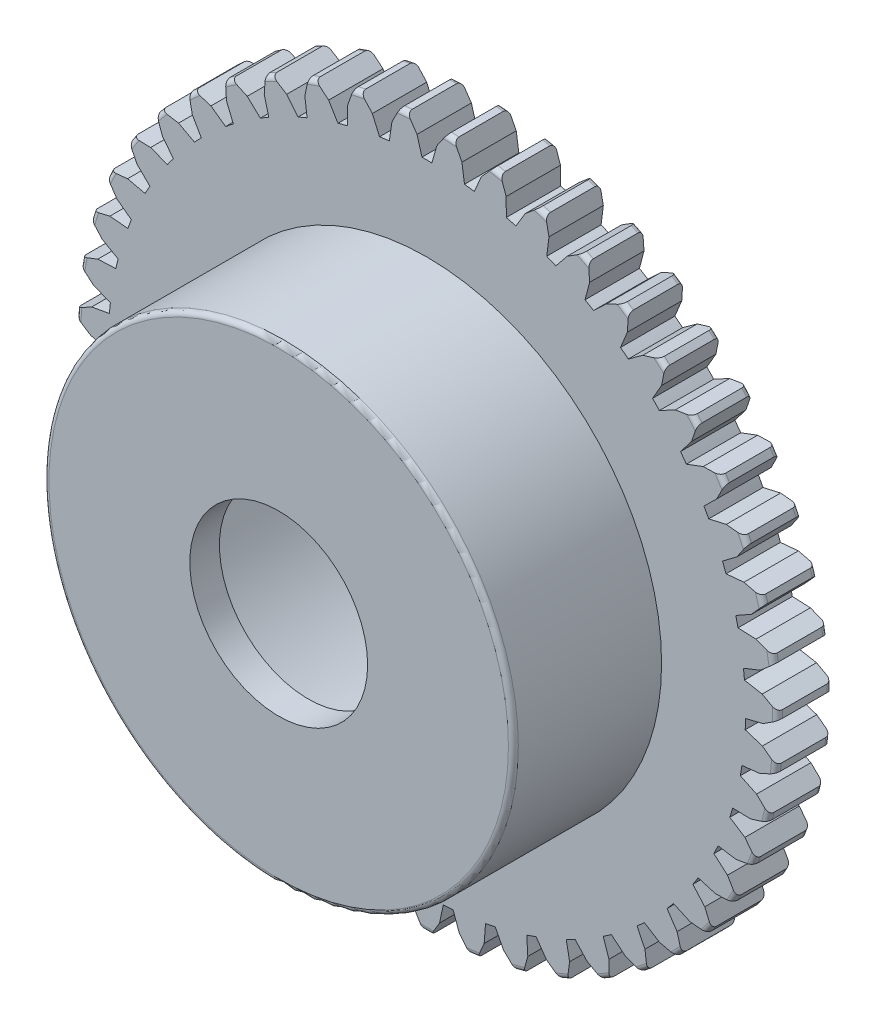
from build123d import *

# Parameters (mm, degrees)
CROQUIS1_R              = 7.1
CROQUIS1_R_2            = 4
SALIENTE_EXTRUIR1_DEPTH = 1.1
CORTAR_EXTRUIR1_DEPTH   = 1.1
REDONDEO2_R             = 0.1
MATRIZC1_COUNT          = 47
CROQUIS4_R              = 4.75
SALIENTE_EXTRUIR2_DEPTH = 3
REDONDEO3_R             = 0.1
CROQUIS2_6_R            = 1.8
CORTAR_EXTRUIR3_DEPTH   = 4.5
CROQUIS1_4_R            = 4
CORTAR_EXTRUIR4_DEPTH   = 3.5


with BuildPart() as part:
    # Croquis1 → Saliente-Extruir1 (new body)
    with BuildSketch(Plane.XY):
        Circle(CROQUIS1_R)
        Circle(CROQUIS1_R_2, mode=Mode.SUBTRACT)
    extrude(amount=SALIENTE_EXTRUIR1_DEPTH)

    # Croquis2 → Cortar-Extruir1 (cut)
    with BuildSketch(Plane.XY.offset(1.1)):
        with BuildLine():
            Line((0.4, 7.088723439), (0.4, 7.202922643))
            Line((0.4, 7.202922643), (-0.4, 7.202922643))
            Line((-0.4, 7.202922643), (-0.4, 7.088723439))
            Line((-0.4, 7.088723439), (-0.2, 6.8))
            Line((-0.2, 6.8), (-0.1, 6.44922476))
            ThreePointArc((-0.1, 6.44922476), (0, 6.45), (0.1, 6.44922476))
            Line((0.1, 6.44922476), (0.2, 6.8))
            Line((0.2, 6.8), (0.4, 7.088723439))
        make_face()
    cortar_extruir1 = extrude(amount=-CORTAR_EXTRUIR1_DEPTH, mode=Mode.SUBTRACT)

    # Redondeo2
    redondeo2_edges = [part.edges().sort_by_distance(p)[0] for p in [
        (0, -7.1, 0),
        (0, -7.1, 1.1),
    ]]
    fillet(redondeo2_edges, radius=REDONDEO2_R)

    # MatrizC1: Cortar-Extruir1 ×47 about axis
    matrizc1_axis = Axis((0, 0, 0), (0, 0, 1))
    for i in range(1, MATRIZC1_COUNT):
        add(cortar_extruir1.rotate(matrizc1_axis, i * 360 / MATRIZC1_COUNT), mode=Mode.SUBTRACT)

    # Croquis4 → Saliente-Extruir2 (add)
    with BuildSketch(Plane.XY.offset(1.1)):
        Circle(CROQUIS4_R)
    extrude(amount=SALIENTE_EXTRUIR2_DEPTH)

    # Redondeo3
    redondeo3_edges = [part.edges().sort_by_distance(p)[0] for p in [
        (-4.75, 0, 4.1),
    ]]
    fillet(redondeo3_edges, radius=REDONDEO3_R)

    # Croquis2_6 → Cortar-Extruir3 (cut)
    with BuildSketch(Plane.XY.offset(1.1)):
        Circle(CROQUIS2_6_R)
    extrude(amount=CORTAR_EXTRUIR3_DEPTH, mode=Mode.SUBTRACT)

    # Croquis1_4 → Cortar-Extruir4 (cut)
    with BuildSketch(Plane.XY):
        Circle(CROQUIS1_4_R)
    extrude(amount=CORTAR_EXTRUIR4_DEPTH, mode=Mode.SUBTRACT)


solid = part.part
